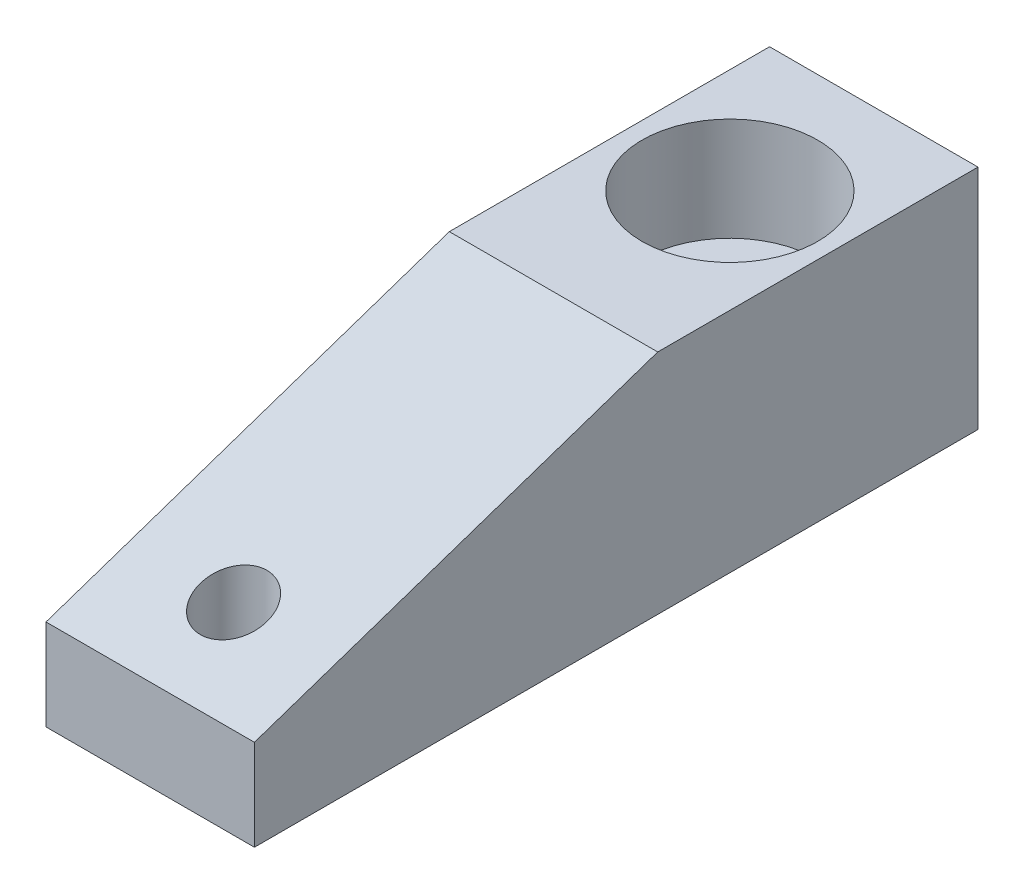
from build123d import *

# Parameters (mm, degrees)
SKETCH1_W          = 16.002
SKETCH1_H          = 55.5498
EXTRUDE1_DEPTH     = 17.4498
FILLET1_R          = 0.381
CUT_EXTRUDE1_DEPTH = 17.002
SKETCH5_R          = 2.5527
CUT_EXTRUDE2_DEPTH = 18.4498


with BuildPart() as part:
    # Sketch1 → Extrude1 (new body)
    with BuildSketch(Plane(origin=(0, 0, 0), x_dir=(1, 0, 0), z_dir=(0, 1, 0))):
        with Locations((8.001, -27.7749)):
            Rectangle(SKETCH1_W, SKETCH1_H)
    extrude(amount=EXTRUDE1_DEPTH)

    # Sketch3 → Cut-Revolve1 (revolve, cut)
    with BuildSketch(Plane(origin=(8.0518, 0, 0), x_dir=(0, 0, -1), z_dir=(1, 0, 0))):
        Polygon((-17.8435, 17.4498), (-17.8435, 9.525), (-15.4686, 9.525), (-15.4686, 6.6548), (-16.941174995, 6.6548), (-17.3482, 0), (-11.0998, 0), (-11.0998, 17.4498), align=None)
    revolve(axis=Axis((8.0518, 31.679444444, 11.0998), (0, -1, 0)), mode=Mode.SUBTRACT)

    # Fillet1
    fillet1_edges = [part.edges().sort_by_distance(p)[0] for p in [
        (8.0518, 6.6548, 5.258425005),
    ]]
    fillet(fillet1_edges, radius=FILLET1_R)

    # Sketch4 → Cut-Extrude1 (cut, through all)
    with BuildSketch(Plane(origin=(16.002, 0, 0), x_dir=(0, 0, -1), z_dir=(1, 0, 0))):
        Polygon((-55.5498, 6.97992), (-55.5498, 17.4498), (-24.5872, 17.4498), align=None)
    extrude(amount=-CUT_EXTRUDE1_DEPTH, mode=Mode.SUBTRACT)

    # Sketch5 → Cut-Extrude2 (cut, through all)
    with BuildSketch(Plane.XZ):
        with Locations(Location((8.0518, 49.1998, 0), (0, 0, 270))):  # turned: the seam where the file's is
            Circle(SKETCH5_R)
    extrude(amount=-CUT_EXTRUDE2_DEPTH, mode=Mode.SUBTRACT)


solid = part.part
